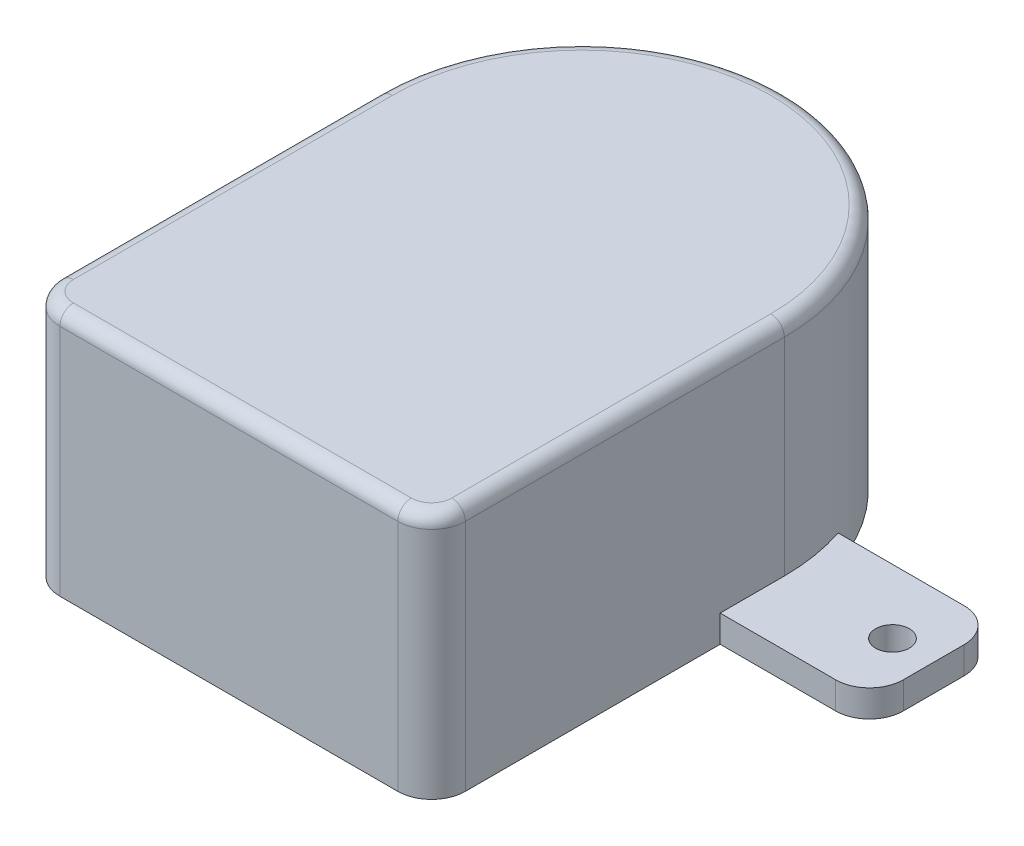
from build123d import *

# Parameters (mm, degrees)
BOSS_EXTRUDE1_DEPTH = 18.3
SKETCH2_R           = 1.25
BOSS_EXTRUDE2_DEPTH = 2
FILLET1_R           = 2.5
SKETCH3_R           = 5.5
CUT_EXTRUDE2_DEPTH  = 5
SKETCH5_R           = 4
CUT_EXTRUDE3_DEPTH  = 15
FILLET2_R           = 1


with BuildPart() as part:
    # Sketch1 → Boss-Extrude1 (new body)
    with BuildSketch(Plane(origin=(0, 0, 0), x_dir=(1, 0, 0), z_dir=(0, 1, 0))):
        with BuildLine():
            Line((-15, 0), (-15, -26.1))
            Line((-15, -26.1), (15, -26.1))
            Line((15, -26.1), (15, 0))
            ThreePointArc((15, 0), (0, 15), (-15, 0))
        make_face()
    extrude(amount=BOSS_EXTRUDE1_DEPTH)

    # Sketch2 → Boss-Extrude2 (add)
    with BuildSketch(Plane(origin=(0, 0, 0), x_dir=(1, 0, 0), z_dir=(0, 1, 0))):
        with BuildLine():
            Line((23.55, -4.75), (-23.55, -4.75))
            ThreePointArc((-23.55, -4.75), (-25.317766953, -4.017766953), (-26.05, -2.25))
            Line((-26.05, -2.25), (-26.05, 2.25))
            ThreePointArc((-26.05, 2.25), (-25.317766953, 4.017766953), (-23.55, 4.75))
            Line((-23.55, 4.75), (23.55, 4.75))
            ThreePointArc((23.55, 4.75), (25.317766953, 4.017766953), (26.05, 2.25))
            Line((26.05, 2.25), (26.05, -2.25))
            ThreePointArc((26.05, -2.25), (25.317766953, -4.017766953), (23.55, -4.75))
        make_face()
        with Locations((-23, 0)):
            Circle(SKETCH2_R, mode=Mode.SUBTRACT)
        with Locations((23, 0)):
            Circle(SKETCH2_R, mode=Mode.SUBTRACT)
    extrude(amount=BOSS_EXTRUDE2_DEPTH)

    # Fillet1
    fillet1_edges = [part.edges().sort_by_distance(p)[0] for p in [
        (15, 9.15, 26.1),
        (-15, 9.15, 26.1),
    ]]
    fillet(fillet1_edges, radius=FILLET1_R)

    # Sketch3 → Cut-Extrude2 (cut)
    with BuildSketch(Plane(origin=(0, 0, 0), x_dir=(-1, 0, 0), z_dir=(0, -1, 0))):
        with Locations((0, 0.1)):
            Circle(SKETCH3_R)
    extrude(amount=-CUT_EXTRUDE2_DEPTH, mode=Mode.SUBTRACT)

    # Sketch5 → Cut-Extrude3 (cut)
    with BuildSketch(Plane(origin=(0, 0, 0), x_dir=(-1, 0, 0), z_dir=(0, -1, 0))):
        with Locations((0, 0.1)):
            Circle(SKETCH5_R)
    extrude(amount=-CUT_EXTRUDE3_DEPTH, mode=Mode.SUBTRACT)

    # Fillet2
    fillet2_edges = [part.edges().sort_by_distance(p)[0] for p in [
        (0, 18.3, -15),
        (0, 18.3, 26.1),
        (15, 18.3, 11.8),
        (14.267766953, 18.3, 25.367766953),
        (-14.267766953, 18.3, 25.367766953),
        (-15, 18.3, 11.8),
    ]]
    fillet(fillet2_edges, radius=FILLET2_R)


solid = part.part
